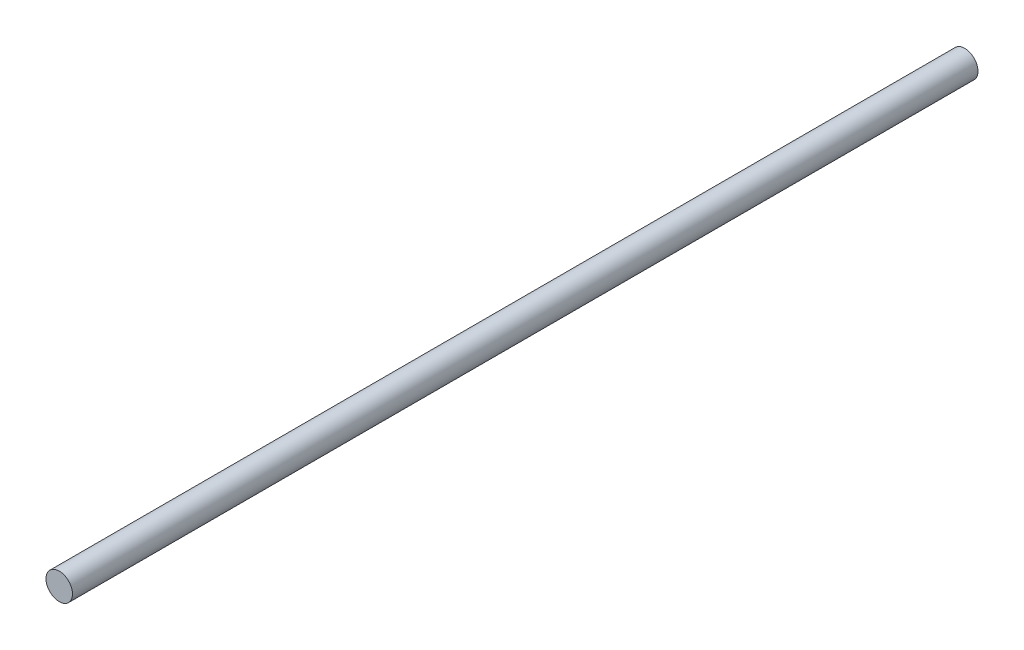
from build123d import *

# Parameters (mm, degrees)
SKETCH2_R           = 6
BOSS_EXTRUDE1_DEPTH = 410


with BuildPart() as part:
    # Sketch2 → Boss-Extrude1 (new body)
    with BuildSketch(Plane.XY):
        Circle(SKETCH2_R)
    extrude(amount=BOSS_EXTRUDE1_DEPTH)


solid = part.part
